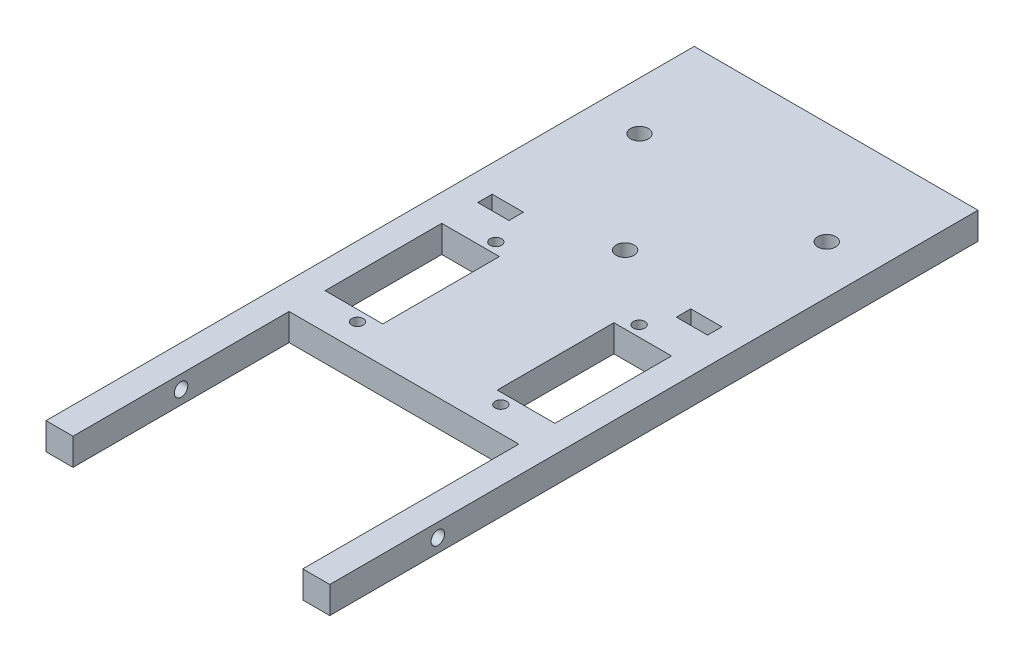
from build123d import *

# Parameters (mm, degrees)
SKETCH1_W               = 100.076
SKETCH1_H               = 228.6
BOSS_EXTRUDE1_DEPTH     = 9.525
SKETCH2_W               = 81.026
SKETCH2_H               = 76.2
CUT_EXTRUDE1_DEPTH      = 10.525
SKETCH3_W               = 20.32
SKETCH3_H               = 41.148
SKETCH3_W_2             = 10.9982
SKETCH3_H_2             = 5.08
CUT_EXTRUDE2_DEPTH      = 10.525
SKETCH4_R               = 2.38125
CUT_EXTRUDE3_DEPTH      = 91.551
CUT_EXTRUDE3_DEPTH_BACK = 10.525
SKETCH6_R               = 3.175
CUT_EXTRUDE5_DEPTH      = 10.525
SKETCH5_R               = 2.032
SKETCH5_R_2             = 3.175
CUT_EXTRUDE4_DEPTH      = 1
CUT_EXTRUDE4_DEPTH_BACK = 10.525


with BuildPart() as part:
    # Sketch1 → Boss-Extrude1 (new body)
    with BuildSketch(Plane(origin=(0, 0, 0), x_dir=(1, 0, 0), z_dir=(0, 1, 0))):
        Rectangle(SKETCH1_W, SKETCH1_H)
    extrude(amount=BOSS_EXTRUDE1_DEPTH)

    # Sketch2 → Cut-Extrude1 (cut, through all)
    with BuildSketch(Plane(origin=(0, 9.525, 0), x_dir=(1, 0, 0), z_dir=(0, 1, 0))):
        with Locations((0, -76.2)):
            Rectangle(SKETCH2_W, SKETCH2_H)
    extrude(amount=-CUT_EXTRUDE1_DEPTH, mode=Mode.SUBTRACT)

    # Sketch3 → Cut-Extrude2 (cut, through all)
    with BuildSketch(Plane(origin=(0, 9.525, 0), x_dir=(1, 0, 0), z_dir=(0, 1, 0))):
        with Locations((-30.353, -4.826)):
            Rectangle(SKETCH3_W, SKETCH3_H)
        with Locations((-35.0139, 30.988)):
            Rectangle(SKETCH3_W_2, SKETCH3_H_2)
        with Locations((30.353, -4.826)):
            Rectangle(SKETCH3_W, SKETCH3_H)
        with Locations((35.0139, 30.988)):
            Rectangle(SKETCH3_W_2, SKETCH3_H_2)
    extrude(amount=-CUT_EXTRUDE2_DEPTH, mode=Mode.SUBTRACT)

    # Sketch4 → Cut-Extrude3 (cut, two sides)
    with BuildSketch(Plane(origin=(-40.513, 0, 0), x_dir=(0, 0, -1), z_dir=(1, 0, 0))) as cut_extrude3_sk:
        with Locations((-76.2, 4.7625)):
            Circle(SKETCH4_R)
    extrude(amount=CUT_EXTRUDE3_DEPTH, mode=Mode.SUBTRACT)
    extrude(cut_extrude3_sk.sketch, amount=-CUT_EXTRUDE3_DEPTH_BACK, mode=Mode.SUBTRACT)

    # Sketch6 → Cut-Extrude5 (cut, through all)
    with BuildSketch(Plane(origin=(0, 9.525, 0), x_dir=(1, 0, 0), z_dir=(0, 1, 0))):
        with Locations((0, 39.878)):
            Circle(SKETCH6_R)
    extrude(amount=-CUT_EXTRUDE5_DEPTH, mode=Mode.SUBTRACT)

    # Sketch5 → Cut-Extrude4 (cut, two sides)
    with BuildSketch(Plane(origin=(0, 9.525, 0), x_dir=(1, 0, 0), z_dir=(0, 1, 0))) as cut_extrude4_sk:
        with Locations((-25.273, 19.558)):
            Circle(SKETCH5_R)
        with Locations((-25.273, -29.21)):
            Circle(SKETCH5_R)
        with Locations((25.273, -29.21)):
            Circle(SKETCH5_R)
        with Locations((25.273, 19.558)):
            Circle(SKETCH5_R)
        with Locations((-33.02, 77.978)):
            Circle(SKETCH5_R_2)
        with Locations((33.02, 77.978)):
            Circle(SKETCH5_R_2)
    extrude(amount=CUT_EXTRUDE4_DEPTH, mode=Mode.SUBTRACT)
    extrude(cut_extrude4_sk.sketch, amount=-CUT_EXTRUDE4_DEPTH_BACK, mode=Mode.SUBTRACT)


solid = part.part
